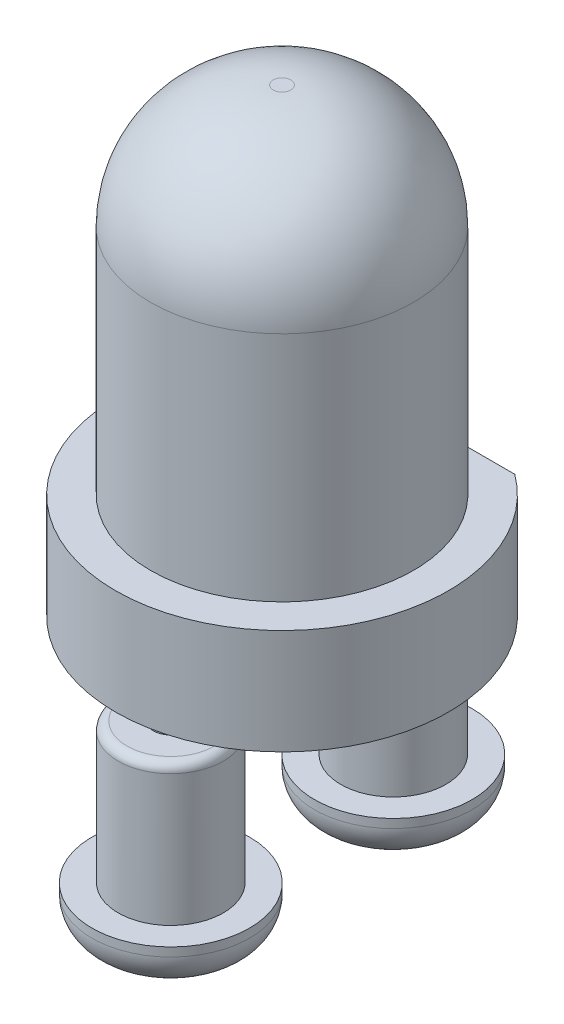
from build123d import *

# Parameters (mm, degrees)
SKETCH2_W               = 3
SKETCH2_H               = 0.5
CUT_EXTRUDE1_DEPTH      = 1.2
SKETCH3_R               = 0.2
BOSS_EXTRUDE1_DEPTH     = 17.5
SKETCH4_R               = 0.2
BOSS_EXTRUDE2_DEPTH     = 1.5
SKETCH5_W               = 5
SKETCH5_H               = 17
CUT_EXTRUDE2_DEPTH      = 2.9
CUT_EXTRUDE2_DEPTH_BACK = 2.9
SKETCH6_R               = 0.9
BOSS_EXTRUDE3_DEPTH     = 0.5
FILLET2_R               = 0.4
SKETCH7_R               = 0.6
BOSS_EXTRUDE4_DEPTH     = 1.6
FILLET3_R               = 0.1


with BuildPart() as part:
    # Sketch1 → Revolve1 (revolve)
    with BuildSketch(Plane.XY):
        with BuildLine():
            Line((0, 0), (0, 5.25))
            Line((0, 5.25), (0.1, 5.25))
            ThreePointArc((0.1, 5.25), (1.089949494, 4.839949494), (1.5, 3.85))
            Line((1.5, 3.85), (1.5, 1.2))
            Line((1.5, 1.2), (1.9, 1.2))
            Line((1.9, 1.2), (1.9, 0))
            Line((1.9, 0), (0, 0))
        make_face()
    revolve(axis=Axis((0, 0, 0), (0, 1, 0)))

    # Sketch2 → Cut-Extrude1 (cut)
    with BuildSketch(Plane(origin=(0, 1.2, 0), x_dir=(1, 0, 0), z_dir=(0, 1, 0))):
        with Locations((0, 1.78)):
            Rectangle(SKETCH2_W, SKETCH2_H)
    extrude(amount=-CUT_EXTRUDE1_DEPTH, mode=Mode.SUBTRACT)

    # Sketch3 → Boss-Extrude1 (add)
    with BuildSketch(Plane.XZ):
        with Locations((0, 1.27)):
            Circle(SKETCH3_R)
        with Locations((0, -1.27)):
            Circle(SKETCH3_R)
    extrude(amount=BOSS_EXTRUDE1_DEPTH)

    # Sketch4 → Boss-Extrude2 (add)
    with BuildSketch(Plane.XZ.offset(17.5)):
        with Locations((0, 1.27)):
            Circle(SKETCH4_R)
    extrude(amount=BOSS_EXTRUDE2_DEPTH)

    # Sketch5 → Cut-Extrude2 (cut, two sides)
    with BuildSketch(Plane(origin=(0, 0, 0), x_dir=(0, 0, -1), z_dir=(1, 0, 0))) as cut_extrude2_sk:
        with Locations((0, -10.5)):
            Rectangle(SKETCH5_W, SKETCH5_H)
    extrude(amount=CUT_EXTRUDE2_DEPTH, mode=Mode.SUBTRACT)
    extrude(cut_extrude2_sk.sketch, amount=-CUT_EXTRUDE2_DEPTH_BACK, mode=Mode.SUBTRACT)

    # Sketch6 → Boss-Extrude3 (add)
    with BuildSketch(Plane.XZ.offset(2)):
        with Locations((0, 1.27)):
            Circle(SKETCH6_R)
        with Locations((0, -1.27)):
            Circle(SKETCH6_R)
    extrude(amount=BOSS_EXTRUDE3_DEPTH)

    # Fillet2
    fillet2_edges = [part.edges().sort_by_distance(p)[0] for p in [
        (-0.9, -2.5, 1.27),
        (-0.9, -2.5, -1.27),
    ]]
    fillet(fillet2_edges, radius=FILLET2_R)

    # Sketch7 → Boss-Extrude4 (add)
    with BuildSketch(Plane(origin=(0, -2, 0), x_dir=(1, 0, 0), z_dir=(0, 1, 0))):
        with Locations((0, -1.27)):
            Circle(SKETCH7_R)
        with Locations((0, 1.27)):
            Circle(SKETCH7_R)
    extrude(amount=BOSS_EXTRUDE4_DEPTH)

    # Fillet3
    fillet3_edges = [part.edges().sort_by_distance(p)[0] for p in [
        (-0.6, -0.4, 1.27),
        (-0.6, -0.4, -1.27),
    ]]
    fillet(fillet3_edges, radius=FILLET3_R)


solid = part.part
